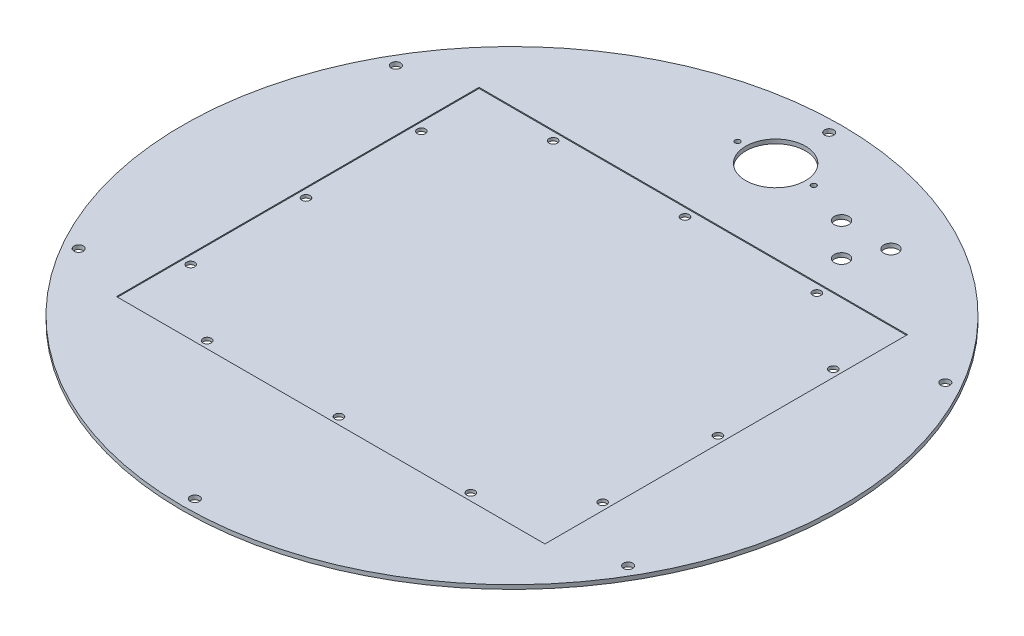
from build123d import *

# Parameters (mm, degrees)
SKETCH1_R                = 508
COVER_DEPTH              = 6.35
COVER_B_C_D              = 14.2875
SKETCH3_W                = 660.4
SKETCH3_H                = 558.8
COVER_HATCH_DEPTH        = 1.5875
COVER_HATCH_BOLT_HOLES_D = 12.7
SKETCH33_R               = 46.0375
COVER_HOLE_ONE_DEPTH     = 7.35
COVER_HOLE_ONE_B_C_D     = 7.9375
SKETCH65_R               = 11.1125
COVER_HOLE_SIX_DEPTH     = 7.35
SKETCH66_R               = 11.1125
COVER_HOLE_SEVEN_DEPTH   = 7.35
SKETCH67_R               = 11.1125
COVER_HOLE_EIGHT_DEPTH   = 7.35


with BuildPart() as part:
    # Sketch1 → Cover (new body)
    with BuildSketch(Plane(origin=(0, 0, 0), x_dir=(1, 0, 0), z_dir=(0, 1, 0))):
        Circle(SKETCH1_R)
    extrude(amount=-COVER_DEPTH)

    # Cover B.C. (through all)
    with Locations(Plane(origin=(0, 0, 0), x_dir=(-1, 0, 0), z_dir=(0, 1, 0))):
        with Locations((0, -488.95), (-423.44312118, -244.475), (-423.44312118, 244.475), (0, 488.95), (423.44312118, 244.475), (423.44312118, -244.475)):
            Hole(COVER_B_C_D / 2)

    # Sketch3 → Cover Hatch (cut)
    with BuildSketch(Plane(origin=(0, 0, 0), x_dir=(-1, 0, 0), z_dir=(0, 1, 0))):
        Rectangle(SKETCH3_W, SKETCH3_H)
    extrude(amount=-COVER_HATCH_DEPTH, mode=Mode.SUBTRACT)

    # Cover Hatch Bolt Holes (through all)
    with Locations(Plane(origin=(0, -1.5875, 0), x_dir=(1, 0, 0), z_dir=(0, 1, 0))):
        with Locations((-317.5, 177.8), (-317.5, 0), (-317.5, -177.8), (317.5, -177.8), (317.5, 0), (317.5, 177.8), (-203.2, 266.7), (0, 266.7), (203.2, 266.7), (203.2, -266.7), (0, -266.7), (-203.2, -266.7)):
            Hole(COVER_HATCH_BOLT_HOLES_D / 2)

    # Sketch33 → Cover Hole One (cut, through all)
    with BuildSketch(Plane(origin=(0, 0, 0), x_dir=(1, 0, 0), z_dir=(0, 1, 0))):
        with Locations((0, 406.4)):
            Circle(SKETCH33_R)
    extrude(amount=-COVER_HOLE_ONE_DEPTH, mode=Mode.SUBTRACT)

    # Cover Hole One B.C. (through all)
    with Locations(Plane(origin=(0, 0, 0), x_dir=(1, 0, 0), z_dir=(0, 1, 0))):
        with Locations((-58.7375, 406.4), (58.7375, 406.4)):
            Hole(COVER_HOLE_ONE_B_C_D / 2)

    # Sketch65 → Cover Hole Six (cut, through all)
    with BuildSketch(Plane(origin=(0, 0, 0), x_dir=(1, 0, 0), z_dir=(0, 1, 0))):
        with Locations((127, 381)):
            Circle(SKETCH65_R)
    extrude(amount=-COVER_HOLE_SIX_DEPTH, mode=Mode.SUBTRACT)

    # Sketch66 → Cover Hole Seven (cut, through all)
    with BuildSketch(Plane(origin=(0, 0, 0), x_dir=(1, 0, 0), z_dir=(0, 1, 0))):
        with Locations((203.2, 381)):
            Circle(SKETCH66_R)
    extrude(amount=-COVER_HOLE_SEVEN_DEPTH, mode=Mode.SUBTRACT)

    # Sketch67 → Cover Hole Eight (cut, through all)
    with BuildSketch(Plane(origin=(0, 0, 0), x_dir=(1, 0, 0), z_dir=(0, 1, 0))):
        with Locations((177.8, 330.2)):
            Circle(SKETCH67_R)
    extrude(amount=-COVER_HOLE_EIGHT_DEPTH, mode=Mode.SUBTRACT)


solid = part.part
